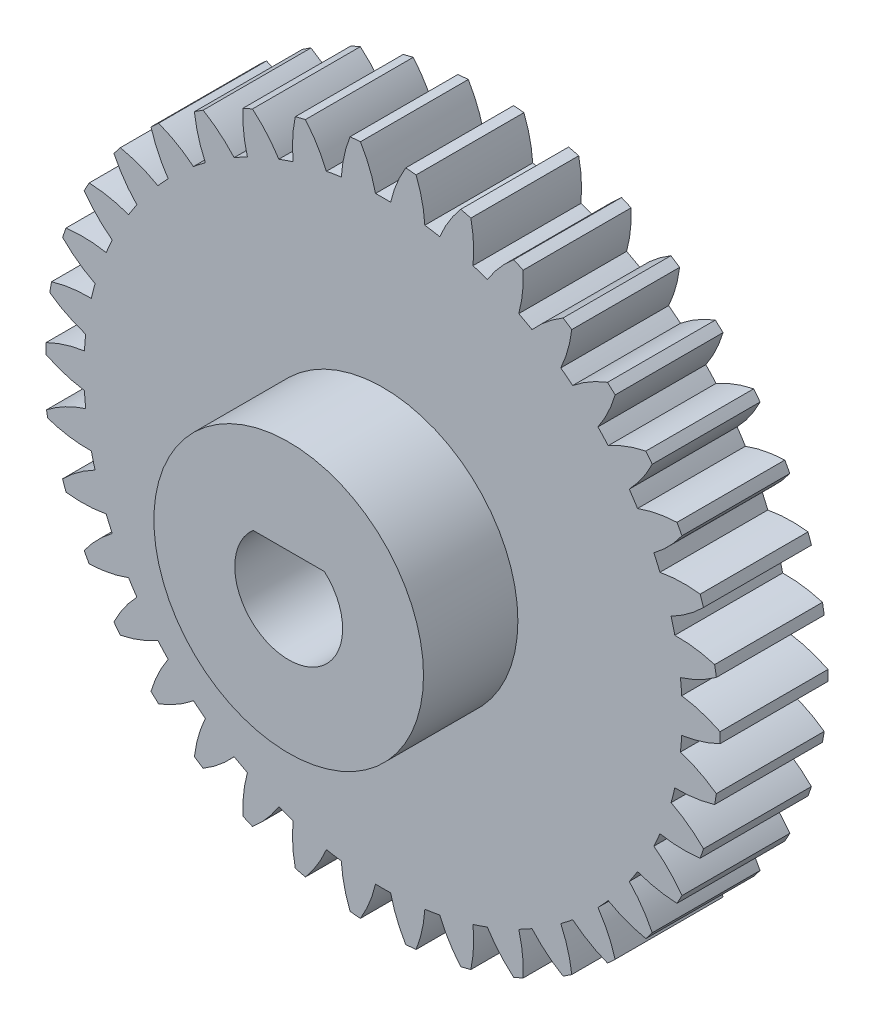
from build123d import *

# Parameters (mm, degrees)
BOSS_EXTRUDE1_DEPTH = 8
SKETCH3_R           = 10
BOSS_EXTRUDE2_DEPTH = 7


with BuildPart() as part:
    # Sketch2 → Boss-Extrude1 (new body)
    with BuildSketch(Plane.XY):
        with BuildLine():
            ThreePointArc((-24.997006848, -0.386844484), (-23.608463747, -0.942373879), (-22.149943267, -1.273104677))
            ThreePointArc((-22.149943267, -1.273104677), (-22.110721854, -1.832146648), (-22.057393054, -2.390019648))
            ThreePointArc((-22.057393054, -2.390019648), (-23.575449075, -3.025155678), (-24.961127611, -3.912729254))
            ThreePointArc((-24.961127611, -3.912729254), (-24.921338049, -4.158635797), (-24.879125979, -4.404138096))
            ThreePointArc((-24.879125979, -4.404138096), (-23.280332659, -4.793691402), (-21.638300768, -4.901502025))
            ThreePointArc((-21.638300768, -4.901502025), (-21.507599, -5.44646376), (-21.363174657, -5.987950468))
            ThreePointArc((-21.363174657, -5.987950468), (-22.63528036, -6.774342185), (-23.768208266, -7.750630673))
            ThreePointArc((-23.768208266, -7.750630673), (-23.645431043, -8.11748673), (-23.516991869, -8.482399038))
            ThreePointArc((-23.516991869, -8.482399038), (-22.023303764, -8.55696911), (-20.536421832, -8.396199175))
            ThreePointArc((-20.536421832, -8.396199175), (-20.317804912, -8.912215539), (-20.086224546, -9.422545608))
            ThreePointArc((-20.086224546, -9.422545608), (-21.211544563, -10.407593684), (-22.168329005, -11.557040674))
            ThreePointArc((-22.168329005, -11.557040674), (-21.98684378, -11.898684826), (-21.800093758, -12.237479812))
            ThreePointArc((-21.800093758, -12.237479812), (-20.314503781, -12.065179864), (-18.874362842, -11.6618699))
            ThreePointArc((-18.874362842, -11.6618699), (-18.57379407, -12.13486531), (-18.26137459, -12.600118267))
            ThreePointArc((-18.26137459, -12.600118267), (-19.209213124, -13.756953158), (-19.963755517, -15.048204732))
            ThreePointArc((-19.963755517, -15.048204732), (-19.728512735, -15.355317817), (-19.488545918, -15.658754038))
            ThreePointArc((-19.488545918, -15.658754038), (-18.051577091, -15.244283963), (-16.697460436, -14.609435213))
            ThreePointArc((-16.697460436, -14.609435213), (-16.323138544, -15.026507589), (-15.938401939, -15.433992545))
            ThreePointArc((-15.938401939, -15.433992545), (-16.682904425, -16.731058811), (-17.21462282, -18.128892993))
            ThreePointArc((-17.21462282, -18.128892993), (-16.932039291, -18.393097767), (-16.645401347, -18.652898273))
            ThreePointArc((-16.645401347, -18.652898273), (-15.296250435, -18.007563734), (-14.065094836, -17.158493218))
            ThreePointArc((-14.065094836, -17.158493218), (-13.62723035, -17.508265912), (-13.180671231, -17.846867741))
            ThreePointArc((-13.180671231, -17.846867741), (-13.701529584, -19.248784795), (-13.995920088, -20.715072312))
            ThreePointArc((-13.995920088, -20.715072312), (-13.673703953, -20.929161957), (-13.34821362, -21.138240068))
            ThreePointArc((-13.34821362, -21.138240068), (-12.123681941, -20.279644109), (-11.049070114, -19.239512257))
            ThreePointArc((-11.049070114, -19.239512257), (-10.559606836, -19.512444381), (-10.063406172, -19.772926907))
            ThreePointArc((-10.063406172, -19.772926907), (-10.346412732, -21.241454107), (-10.39544514, -22.736198458))
            ThreePointArc((-10.39544514, -22.736198458), (-10.042385616, -22.894333166), (-9.686921421, -23.046985776))
            ThreePointArc((-9.686921421, -23.046985776), (-8.620411009, -21.998548658), (-7.731655562, -20.795727555))
            ThreePointArc((-7.731655562, -20.795727555), (-7.203944774, -20.984374233), (-6.671637625, -21.159632172))
            ThreePointArc((-6.671637625, -21.159632172), (-6.709072712, -22.654711924), (-6.511409548, -24.137140379))
            ThreePointArc((-6.511409548, -24.137140379), (-6.137137179, -24.235006648), (-5.761395258, -24.327069792))
            ThreePointArc((-5.761395258, -24.327069792), (-4.881997735, -23.117390145), (-4.203341601, -21.784689615))
            ThreePointArc((-4.203341601, -21.784689615), (-3.651777877, -21.883905058), (-3.097884196, -21.96915783))
            ThreePointArc((-3.097884196, -21.96915783), (-2.888726678, -23.450008256), (-2.449759678, -24.879684032))
            ThreePointArc((-2.449759678, -24.879684032), (-2.064483637, -24.914612325), (-1.678713251, -24.94357476))
            ThreePointArc((-1.678713251, -24.94357476), (-1.01041629, -23.605649492), (-0.560371438, -22.179422132))
            ThreePointArc((-0.560371438, -22.179422132), (0, -22.1865), (0.560371438, -22.179422132))
            ThreePointArc((0.560371438, -22.179422132), (1.01041629, -23.605649492), (1.678713251, -24.94357476))
            ThreePointArc((1.678713251, -24.94357476), (2.064483637, -24.914612325), (2.449759678, -24.879684032))
            ThreePointArc((2.449759678, -24.879684032), (2.888726678, -23.450008256), (3.097884196, -21.96915783))
            ThreePointArc((3.097884196, -21.96915783), (3.651777877, -21.883905058), (4.203341601, -21.784689615))
            ThreePointArc((4.203341601, -21.784689615), (4.881997735, -23.117390145), (5.761395258, -24.327069792))
            ThreePointArc((5.761395258, -24.327069792), (6.137137179, -24.235006648), (6.511409548, -24.137140379))
            ThreePointArc((6.511409548, -24.137140379), (6.709072712, -22.654711924), (6.671637625, -21.159632172))
            ThreePointArc((6.671637625, -21.159632172), (7.203944774, -20.984374233), (7.731655562, -20.795727555))
            ThreePointArc((7.731655562, -20.795727555), (8.620411009, -21.998548658), (9.686921421, -23.046985776))
            ThreePointArc((9.686921421, -23.046985776), (10.042385616, -22.894333166), (10.39544514, -22.736198458))
            ThreePointArc((10.39544514, -22.736198458), (10.346412732, -21.241454107), (10.063406172, -19.772926907))
            ThreePointArc((10.063406172, -19.772926907), (10.559606836, -19.512444381), (11.049070114, -19.239512257))
            ThreePointArc((11.049070114, -19.239512257), (12.123681941, -20.279644109), (13.34821362, -21.138240068))
            ThreePointArc((13.34821362, -21.138240068), (13.673703953, -20.929161957), (13.995920088, -20.715072312))
            ThreePointArc((13.995920088, -20.715072312), (13.701529584, -19.248784795), (13.180671231, -17.846867741))
            ThreePointArc((13.180671231, -17.846867741), (13.62723035, -17.508265912), (14.065094836, -17.158493218))
            ThreePointArc((14.065094836, -17.158493218), (15.296250435, -18.007563734), (16.645401347, -18.652898273))
            ThreePointArc((16.645401347, -18.652898273), (16.932039291, -18.393097767), (17.21462282, -18.128892993))
            ThreePointArc((17.21462282, -18.128892993), (16.682904425, -16.731058811), (15.938401939, -15.433992545))
            ThreePointArc((15.938401939, -15.433992545), (16.323138544, -15.026507589), (16.697460436, -14.609435213))
            ThreePointArc((16.697460436, -14.609435213), (18.051577091, -15.244283963), (19.488545918, -15.658754038))
            ThreePointArc((19.488545918, -15.658754038), (19.728512735, -15.355317817), (19.963755517, -15.048204732))
            ThreePointArc((19.963755517, -15.048204732), (19.209213124, -13.756953158), (18.26137459, -12.600118267))
            ThreePointArc((18.26137459, -12.600118267), (18.57379407, -12.13486531), (18.874362842, -11.6618699))
            ThreePointArc((18.874362842, -11.6618699), (20.314503781, -12.065179864), (21.800093758, -12.237479812))
            ThreePointArc((21.800093758, -12.237479812), (21.98684378, -11.898684826), (22.168329005, -11.557040674))
            ThreePointArc((22.168329005, -11.557040674), (21.211544563, -10.407593684), (20.086224546, -9.422545608))
            ThreePointArc((20.086224546, -9.422545608), (20.317804912, -8.912215539), (20.536421832, -8.396199175))
            ThreePointArc((20.536421832, -8.396199175), (22.023303764, -8.55696911), (23.516991869, -8.482399038))
            ThreePointArc((23.516991869, -8.482399038), (23.645431043, -8.11748673), (23.768208266, -7.750630673))
            ThreePointArc((23.768208266, -7.750630673), (22.63528036, -6.774342185), (21.363174657, -5.987950468))
            ThreePointArc((21.363174657, -5.987950468), (21.507599, -5.44646376), (21.638300768, -4.901502025))
            ThreePointArc((21.638300768, -4.901502025), (23.13136543, -4.815346545), (24.592407746, -4.495940529))
            ThreePointArc((24.592407746, -4.495940529), (24.659032585, -4.114864757), (24.719752765, -3.732803671))
            ThreePointArc((24.719752765, -3.732803671), (23.441584715, -2.95630429), (22.057393054, -2.390019648))
            ThreePointArc((22.057393054, -2.390019648), (22.110721854, -1.832146648), (22.149943267, -1.273104677))
            ThreePointArc((22.149943267, -1.273104677), (23.608463747, -0.942373879), (24.997006848, -0.386844484))
            ThreePointArc((24.997006848, -0.386844484), (25, 0), (24.997006848, 0.386844484))
            ThreePointArc((24.997006848, 0.386844484), (23.608463747, 0.942373879), (22.149943267, 1.273104677))
            ThreePointArc((22.149943267, 1.273104677), (22.110721854, 1.832146648), (22.057393054, 2.390019648))
            ThreePointArc((22.057393054, 2.390019648), (23.441584715, 2.95630429), (24.719752765, 3.732803671))
            ThreePointArc((24.719752765, 3.732803671), (24.659032585, 4.114864757), (24.592407746, 4.495940529))
            ThreePointArc((24.592407746, 4.495940529), (23.13136543, 4.815346545), (21.638300768, 4.901502025))
            ThreePointArc((21.638300768, 4.901502025), (21.507599, 5.44646376), (21.363174657, 5.987950468))
            ThreePointArc((21.363174657, 5.987950468), (22.63528036, 6.774342185), (23.768208266, 7.750630673))
            ThreePointArc((23.768208266, 7.750630673), (23.645431043, 8.11748673), (23.516991869, 8.482399038))
            ThreePointArc((23.516991869, 8.482399038), (22.023303764, 8.55696911), (20.536421832, 8.396199175))
            ThreePointArc((20.536421832, 8.396199175), (20.317804912, 8.912215539), (20.086224546, 9.422545608))
            ThreePointArc((20.086224546, 9.422545608), (21.211544563, 10.407593684), (22.168329005, 11.557040674))
            ThreePointArc((22.168329005, 11.557040674), (21.98684378, 11.898684826), (21.800093758, 12.237479812))
            ThreePointArc((21.800093758, 12.237479812), (20.314503781, 12.065179864), (18.874362842, 11.6618699))
            ThreePointArc((18.874362842, 11.6618699), (18.57379407, 12.13486531), (18.26137459, 12.600118267))
            ThreePointArc((18.26137459, 12.600118267), (19.209213124, 13.756953158), (19.963755517, 15.048204732))
            ThreePointArc((19.963755517, 15.048204732), (19.728512735, 15.355317817), (19.488545918, 15.658754038))
            ThreePointArc((19.488545918, 15.658754038), (18.051577091, 15.244283963), (16.697460436, 14.609435213))
            ThreePointArc((16.697460436, 14.609435213), (16.323138544, 15.026507589), (15.938401939, 15.433992545))
            ThreePointArc((15.938401939, 15.433992545), (16.682904425, 16.731058811), (17.21462282, 18.128892993))
            ThreePointArc((17.21462282, 18.128892993), (16.932039291, 18.393097767), (16.645401347, 18.652898273))
            ThreePointArc((16.645401347, 18.652898273), (15.296250435, 18.007563734), (14.065094836, 17.158493218))
            ThreePointArc((14.065094836, 17.158493218), (13.62723035, 17.508265912), (13.180671231, 17.846867741))
            ThreePointArc((13.180671231, 17.846867741), (13.701529584, 19.248784795), (13.995920088, 20.715072312))
            ThreePointArc((13.995920088, 20.715072312), (13.673703953, 20.929161957), (13.34821362, 21.138240068))
            ThreePointArc((13.34821362, 21.138240068), (12.123681941, 20.279644109), (11.049070114, 19.239512257))
            ThreePointArc((11.049070114, 19.239512257), (10.559606836, 19.512444381), (10.063406172, 19.772926907))
            ThreePointArc((10.063406172, 19.772926907), (10.346412732, 21.241454107), (10.39544514, 22.736198458))
            ThreePointArc((10.39544514, 22.736198458), (10.042385616, 22.894333166), (9.686921421, 23.046985776))
            ThreePointArc((9.686921421, 23.046985776), (8.620411009, 21.998548658), (7.731655562, 20.795727555))
            ThreePointArc((7.731655562, 20.795727555), (7.203944774, 20.984374233), (6.671637625, 21.159632172))
            ThreePointArc((6.671637625, 21.159632172), (6.709072712, 22.654711924), (6.511409548, 24.137140379))
            ThreePointArc((6.511409548, 24.137140379), (6.137137179, 24.235006648), (5.761395258, 24.327069792))
            ThreePointArc((5.761395258, 24.327069792), (4.881997735, 23.117390145), (4.203341601, 21.784689615))
            ThreePointArc((4.203341601, 21.784689615), (3.651777877, 21.883905058), (3.097884196, 21.96915783))
            ThreePointArc((3.097884196, 21.96915783), (2.888726678, 23.450008256), (2.449759678, 24.879684032))
            ThreePointArc((2.449759678, 24.879684032), (2.064483637, 24.914612325), (1.678713251, 24.94357476))
            ThreePointArc((1.678713251, 24.94357476), (1.01041629, 23.605649492), (0.560371438, 22.179422132))
            ThreePointArc((0.560371438, 22.179422132), (0, 22.1865), (-0.560371438, 22.179422132))
            ThreePointArc((-0.560371438, 22.179422132), (-1.01041629, 23.605649492), (-1.678713251, 24.94357476))
            ThreePointArc((-1.678713251, 24.94357476), (-2.064483637, 24.914612325), (-2.449759678, 24.879684032))
            ThreePointArc((-2.449759678, 24.879684032), (-2.888726678, 23.450008256), (-3.097884196, 21.96915783))
            ThreePointArc((-3.097884196, 21.96915783), (-3.651777877, 21.883905058), (-4.203341601, 21.784689615))
            ThreePointArc((-4.203341601, 21.784689615), (-4.881997735, 23.117390145), (-5.761395258, 24.327069792))
            ThreePointArc((-5.761395258, 24.327069792), (-6.137137179, 24.235006648), (-6.511409548, 24.137140379))
            ThreePointArc((-6.511409548, 24.137140379), (-6.709072712, 22.654711924), (-6.671637625, 21.159632172))
            ThreePointArc((-6.671637625, 21.159632172), (-7.203944774, 20.984374233), (-7.731655562, 20.795727555))
            ThreePointArc((-7.731655562, 20.795727555), (-8.620411009, 21.998548658), (-9.686921421, 23.046985776))
            ThreePointArc((-9.686921421, 23.046985776), (-10.042385616, 22.894333166), (-10.39544514, 22.736198458))
            ThreePointArc((-10.39544514, 22.736198458), (-10.346412732, 21.241454107), (-10.063406172, 19.772926907))
            ThreePointArc((-10.063406172, 19.772926907), (-10.559606836, 19.512444381), (-11.049070114, 19.239512257))
            ThreePointArc((-11.049070114, 19.239512257), (-12.123681941, 20.279644109), (-13.34821362, 21.138240068))
            ThreePointArc((-13.34821362, 21.138240068), (-13.673703953, 20.929161957), (-13.995920088, 20.715072312))
            ThreePointArc((-13.995920088, 20.715072312), (-13.701529584, 19.248784795), (-13.180671231, 17.846867741))
            ThreePointArc((-13.180671231, 17.846867741), (-13.62723035, 17.508265912), (-14.065094836, 17.158493218))
            ThreePointArc((-14.065094836, 17.158493218), (-15.296250435, 18.007563734), (-16.645401347, 18.652898273))
            ThreePointArc((-16.645401347, 18.652898273), (-16.932039291, 18.393097767), (-17.21462282, 18.128892993))
            ThreePointArc((-17.21462282, 18.128892993), (-16.682904425, 16.731058811), (-15.938401939, 15.433992545))
            ThreePointArc((-15.938401939, 15.433992545), (-16.323138544, 15.026507589), (-16.697460436, 14.609435213))
            ThreePointArc((-16.697460436, 14.609435213), (-18.051577091, 15.244283963), (-19.488545918, 15.658754038))
            ThreePointArc((-19.488545918, 15.658754038), (-19.728512735, 15.355317817), (-19.963755517, 15.048204732))
            ThreePointArc((-19.963755517, 15.048204732), (-19.209213124, 13.756953158), (-18.26137459, 12.600118267))
            ThreePointArc((-18.26137459, 12.600118267), (-18.57379407, 12.13486531), (-18.874362842, 11.6618699))
            ThreePointArc((-18.874362842, 11.6618699), (-20.314503781, 12.065179864), (-21.800093758, 12.237479812))
            ThreePointArc((-21.800093758, 12.237479812), (-21.98684378, 11.898684826), (-22.168329005, 11.557040674))
            ThreePointArc((-22.168329005, 11.557040674), (-21.211544563, 10.407593684), (-20.086224546, 9.422545608))
            ThreePointArc((-20.086224546, 9.422545608), (-20.317804912, 8.912215539), (-20.536421832, 8.396199175))
            ThreePointArc((-20.536421832, 8.396199175), (-22.023303764, 8.55696911), (-23.516991869, 8.482399038))
            ThreePointArc((-23.516991869, 8.482399038), (-23.645431043, 8.11748673), (-23.768208266, 7.750630673))
            ThreePointArc((-23.768208266, 7.750630673), (-22.63528036, 6.774342185), (-21.363174657, 5.987950468))
            ThreePointArc((-21.363174657, 5.987950468), (-21.507599, 5.44646376), (-21.638300768, 4.901502025))
            ThreePointArc((-21.638300768, 4.901502025), (-23.13136543, 4.815346545), (-24.592407746, 4.495940529))
            ThreePointArc((-24.592407746, 4.495940529), (-24.659032585, 4.114864757), (-24.719752765, 3.732803671))
            ThreePointArc((-24.719752765, 3.732803671), (-23.441584715, 2.95630429), (-22.057393054, 2.390019648))
            ThreePointArc((-22.057393054, 2.390019648), (-22.110721854, 1.832146648), (-22.149943267, 1.273104677))
            ThreePointArc((-22.149943267, 1.273104677), (-23.608463747, 0.942373879), (-24.997006848, 0.386844484))
            ThreePointArc((-24.997006848, 0.386844484), (-25, 0), (-24.997006848, -0.386844484))
        make_face()
        with BuildLine():
            Line((2.645751345, 2.99999997), (-2.645751345, 2.99999997))
            ThreePointArc((-2.645751345, 2.99999997), (0, -4), (2.645751345, 2.99999997))
        make_face(mode=Mode.SUBTRACT)
    extrude(amount=BOSS_EXTRUDE1_DEPTH)

    # Sketch3 → Boss-Extrude2 (add)
    with BuildSketch(Plane.XY.offset(8)):
        Circle(SKETCH3_R)
        with BuildLine():
            Line((2.645751345, 2.99999997), (-2.645751345, 2.99999997))
            ThreePointArc((-2.645751345, 2.99999997), (0, -4), (2.645751345, 2.99999997))
        make_face(mode=Mode.SUBTRACT)
    extrude(amount=BOSS_EXTRUDE2_DEPTH)


solid = part.part
